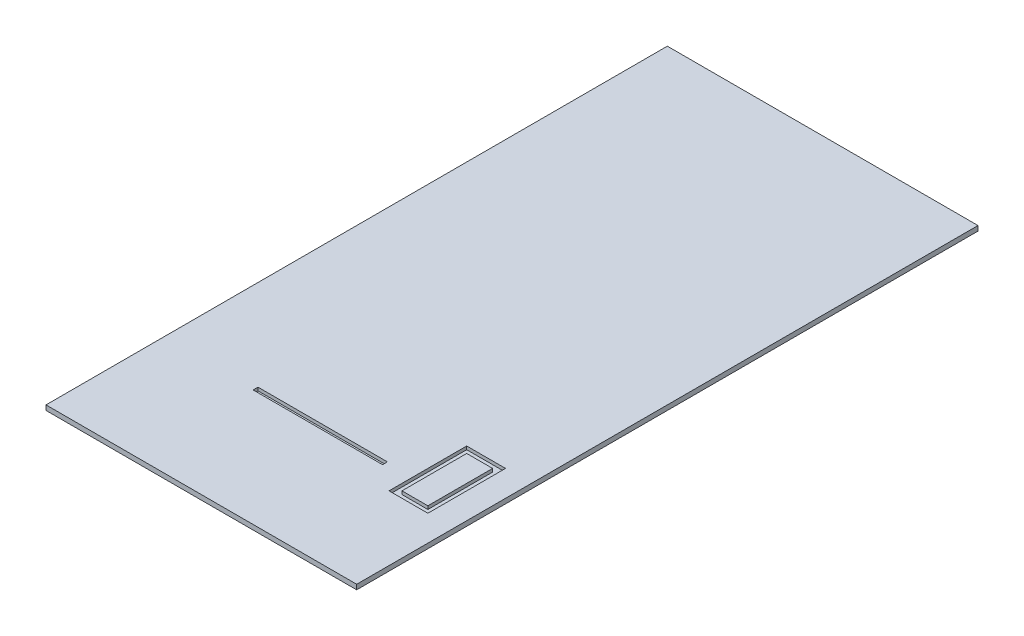
from build123d import *

# Parameters (mm, degrees)
SKETCH1_W           = 1219.2
SKETCH1_H           = 2438.4
BOSS_EXTRUDE1_DEPTH = 19.05
SKETCH2_W           = 152.4
SKETCH2_H           = 304.8
SKETCH2_W_2         = 101.6
SKETCH2_H_2         = 254
CUT_EXTRUDE1_DEPTH  = 12.7
SKETCH3_W           = 508
SKETCH3_H           = 19.05
CUT_EXTRUDE2_DEPTH  = 12.7


with BuildPart() as part:
    # Sketch1 → Boss-Extrude1 (new body)
    with BuildSketch(Plane(origin=(0, 0, 0), x_dir=(1, 0, 0), z_dir=(0, 1, 0))):
        Rectangle(SKETCH1_W, SKETCH1_H)
    extrude(amount=BOSS_EXTRUDE1_DEPTH)

    # Sketch2 → Cut-Extrude1 (cut)
    with BuildSketch(Plane(origin=(0, 19.05, 0), x_dir=(1, 0, 0), z_dir=(0, 1, 0))):
        with Locations((431.8, -685.8)):
            Rectangle(SKETCH2_W, SKETCH2_H)
        with Locations((431.8, -685.8)):
            Rectangle(SKETCH2_W_2, SKETCH2_H_2, mode=Mode.SUBTRACT)
    extrude(amount=-CUT_EXTRUDE1_DEPTH, mode=Mode.SUBTRACT)

    # Sketch3 → Cut-Extrude2 (cut)
    with BuildSketch(Plane(origin=(0, 19.05, 0), x_dir=(1, 0, 0), z_dir=(0, 1, 0))):
        with Locations((0, -752.475)):
            Rectangle(SKETCH3_W, SKETCH3_H)
    extrude(amount=-CUT_EXTRUDE2_DEPTH, mode=Mode.SUBTRACT)


solid = part.part
